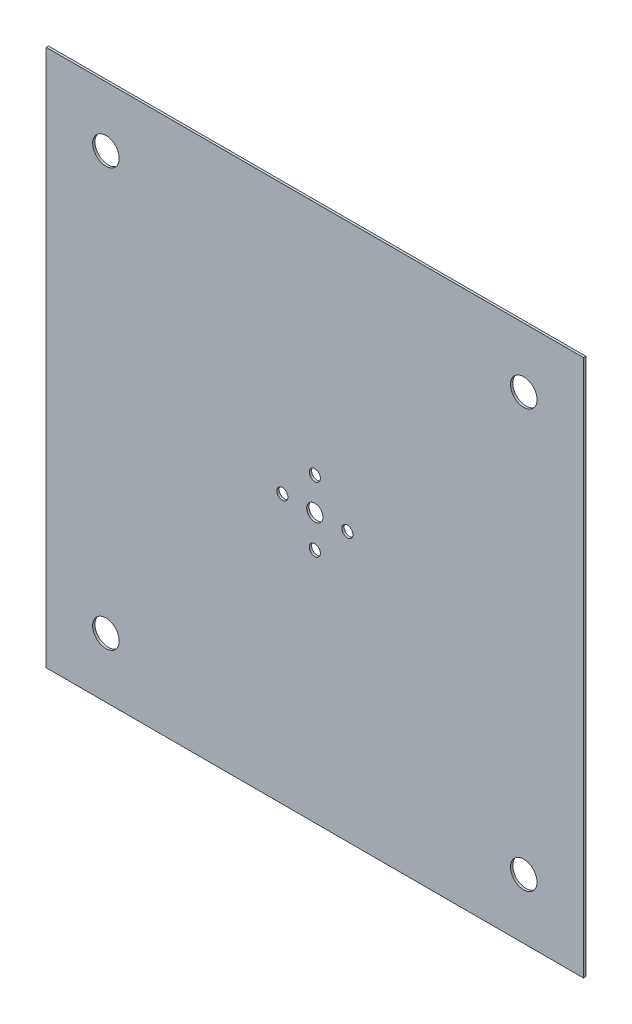
from build123d import *

# Parameters (mm, degrees)
SKETCH1_W           = 2314.8
SKETCH1_H           = 2314.8
BOSS_EXTRUDE1_DEPTH = 10
SKETCH2_R           = 35
SKETCH2_R_2         = 23.9
SKETCH2_R_3         = 57.15
CUT_EXTRUDE1_DEPTH  = 10


with BuildPart() as part:
    # Sketch1 → Boss-Extrude1 (new body)
    with BuildSketch(Plane.XY):
        Rectangle(SKETCH1_W, SKETCH1_H)
    extrude(amount=BOSS_EXTRUDE1_DEPTH)

    # Sketch2 → Cut-Extrude1 (cut)
    with BuildSketch(Plane.XY.offset(10)):
        Circle(SKETCH2_R)
        with Locations((0, 140)):
            Circle(SKETCH2_R_2)
        with Locations((0, -140)):
            Circle(SKETCH2_R_2)
        with Locations((140, 0)):
            Circle(SKETCH2_R_2)
        with Locations((-140, 0)):
            Circle(SKETCH2_R_2)
        with Locations((-900, 900)):
            Circle(SKETCH2_R_3)
        with Locations((900, 900)):
            Circle(SKETCH2_R_3)
        with Locations((900, -900)):
            Circle(SKETCH2_R_3)
        with Locations((-900, -900)):
            Circle(SKETCH2_R_3)
    extrude(amount=-CUT_EXTRUDE1_DEPTH, mode=Mode.SUBTRACT)


solid = part.part
